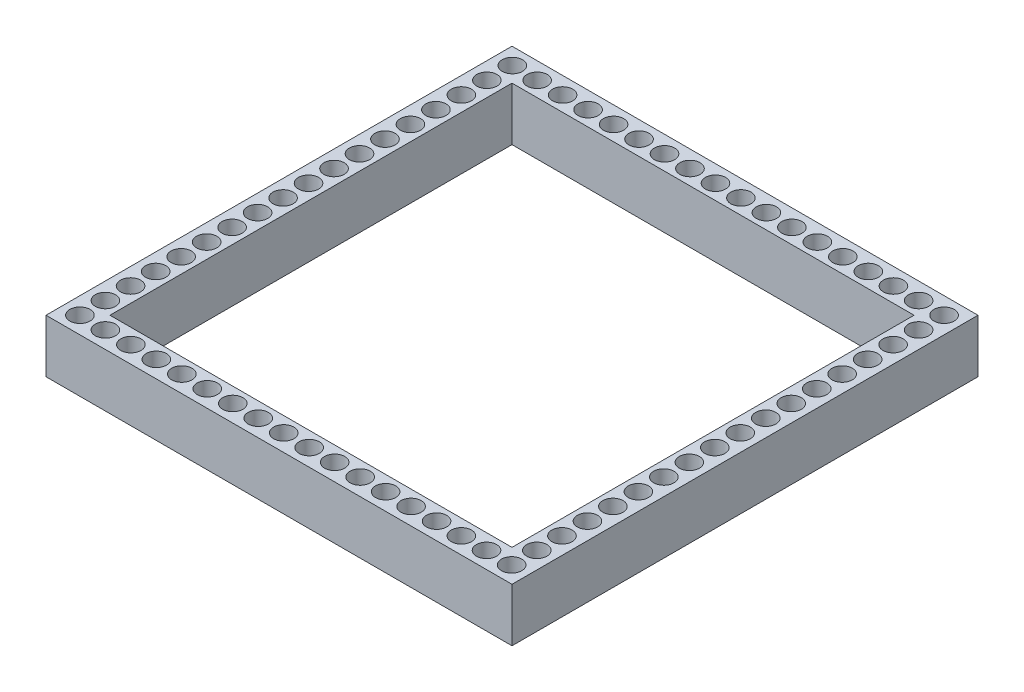
from build123d import *

# Parameters (mm, degrees)
SKETCH2_W           = 43.72
SKETCH2_H           = 43.72
SKETCH2_W_2         = 37.72
SKETCH2_H_2         = 37.72
BOSS_EXTRUDE1_DEPTH = 5
SKETCH1_R           = 0.95
CUT_EXTRUDE1_DEPTH  = 6


with BuildPart() as part:
    # Sketch2 → Boss-Extrude1 (new body)
    with BuildSketch(Plane(origin=(0, 0, 0), x_dir=(1, 0, 0), z_dir=(0, 1, 0))):
        Rectangle(SKETCH2_W, SKETCH2_H)
        Rectangle(SKETCH2_W_2, SKETCH2_H_2, mode=Mode.SUBTRACT)
    extrude(amount=BOSS_EXTRUDE1_DEPTH)

    # Sketch1 → Cut-Extrude1 (cut, through all)
    with BuildSketch(Plane(origin=(0, 0, 0), x_dir=(1, 0, 0), z_dir=(0, 1, 0))):
        with Locations((-20.269, -20.269)):
            Circle(SKETCH1_R)
        with Locations((-17.879, -20.269)):
            Circle(SKETCH1_R)
        with Locations((-15.489, -20.269)):
            Circle(SKETCH1_R)
        with Locations((-13.099, -20.269)):
            Circle(SKETCH1_R)
        with Locations((-10.709, -20.269)):
            Circle(SKETCH1_R)
        with Locations((-8.319, -20.269)):
            Circle(SKETCH1_R)
        with Locations((-5.929, -20.269)):
            Circle(SKETCH1_R)
        with Locations((-3.539, -20.269)):
            Circle(SKETCH1_R)
        with Locations((-1.149, -20.269)):
            Circle(SKETCH1_R)
        with Locations((1.241, -20.269)):
            Circle(SKETCH1_R)
        with Locations((3.631, -20.269)):
            Circle(SKETCH1_R)
        with Locations((6.021, -20.269)):
            Circle(SKETCH1_R)
        with Locations((8.411, -20.269)):
            Circle(SKETCH1_R)
        with Locations((10.801, -20.269)):
            Circle(SKETCH1_R)
        with Locations((13.191, -20.269)):
            Circle(SKETCH1_R)
        with Locations((20.269, 20.269)):
            Circle(SKETCH1_R)
        with Locations((20.269, -15.581)):
            Circle(SKETCH1_R)
        with Locations((20.269, -13.191)):
            Circle(SKETCH1_R)
        with Locations((20.269, -10.801)):
            Circle(SKETCH1_R)
        with Locations((20.269, -8.411)):
            Circle(SKETCH1_R)
        with Locations((20.269, -6.021)):
            Circle(SKETCH1_R)
        with Locations((20.269, -3.631)):
            Circle(SKETCH1_R)
        with Locations((20.269, -1.241)):
            Circle(SKETCH1_R)
        with Locations((20.269, 1.149)):
            Circle(SKETCH1_R)
        with Locations((20.269, 3.539)):
            Circle(SKETCH1_R)
        with Locations((20.269, 5.929)):
            Circle(SKETCH1_R)
        with Locations((20.269, 8.319)):
            Circle(SKETCH1_R)
        with Locations((20.269, 10.709)):
            Circle(SKETCH1_R)
        with Locations((20.269, 13.099)):
            Circle(SKETCH1_R)
        with Locations((20.269, 15.489)):
            Circle(SKETCH1_R)
        with Locations((20.269, 17.879)):
            Circle(SKETCH1_R)
        with Locations((13.159, 20.269)):
            Circle(SKETCH1_R)
        with Locations((10.769, 20.269)):
            Circle(SKETCH1_R)
        with Locations((8.379, 20.269)):
            Circle(SKETCH1_R)
        with Locations((5.989, 20.269)):
            Circle(SKETCH1_R)
        with Locations((3.599, 20.269)):
            Circle(SKETCH1_R)
        with Locations((1.209, 20.269)):
            Circle(SKETCH1_R)
        with Locations((-1.181, 20.269)):
            Circle(SKETCH1_R)
        with Locations((-3.571, 20.269)):
            Circle(SKETCH1_R)
        with Locations((-5.961, 20.269)):
            Circle(SKETCH1_R)
        with Locations((-8.351, 20.269)):
            Circle(SKETCH1_R)
        with Locations((-10.741, 20.269)):
            Circle(SKETCH1_R)
        with Locations((-13.131, 20.269)):
            Circle(SKETCH1_R)
        with Locations((-15.521, 20.269)):
            Circle(SKETCH1_R)
        with Locations((-17.911, 20.269)):
            Circle(SKETCH1_R)
        with Locations((-20.269, 20.301)):
            Circle(SKETCH1_R)
        with Locations((-20.269, 17.911)):
            Circle(SKETCH1_R)
        with Locations((-20.269, 15.521)):
            Circle(SKETCH1_R)
        with Locations((-20.269, 13.131)):
            Circle(SKETCH1_R)
        with Locations((-20.269, 10.741)):
            Circle(SKETCH1_R)
        with Locations((-20.269, 8.351)):
            Circle(SKETCH1_R)
        with Locations((-20.269, 5.961)):
            Circle(SKETCH1_R)
        with Locations((-20.269, 3.571)):
            Circle(SKETCH1_R)
        with Locations((-20.269, 1.181)):
            Circle(SKETCH1_R)
        with Locations((-20.269, -1.209)):
            Circle(SKETCH1_R)
        with Locations((-20.269, -3.599)):
            Circle(SKETCH1_R)
        with Locations((-20.269, -5.989)):
            Circle(SKETCH1_R)
        with Locations((-20.269, -8.379)):
            Circle(SKETCH1_R)
        with Locations((-20.269, -10.769)):
            Circle(SKETCH1_R)
        with Locations((-20.269, -13.159)):
            Circle(SKETCH1_R)
        with Locations((-20.269, -15.519)):
            Circle(SKETCH1_R)
        with Locations((-20.269, -17.879)):
            Circle(SKETCH1_R)
        with Locations((15.519, 20.269)):
            Circle(SKETCH1_R)
        with Locations((17.879, 20.269)):
            Circle(SKETCH1_R)
        with Locations((20.269, -17.941)):
            Circle(SKETCH1_R)
        with Locations((20.269, -20.301)):
            Circle(SKETCH1_R)
        with Locations((17.909, -20.301)):
            Circle(SKETCH1_R)
        with Locations((15.549, -20.301)):
            Circle(SKETCH1_R)
    extrude(amount=CUT_EXTRUDE1_DEPTH, mode=Mode.SUBTRACT)


solid = part.part
